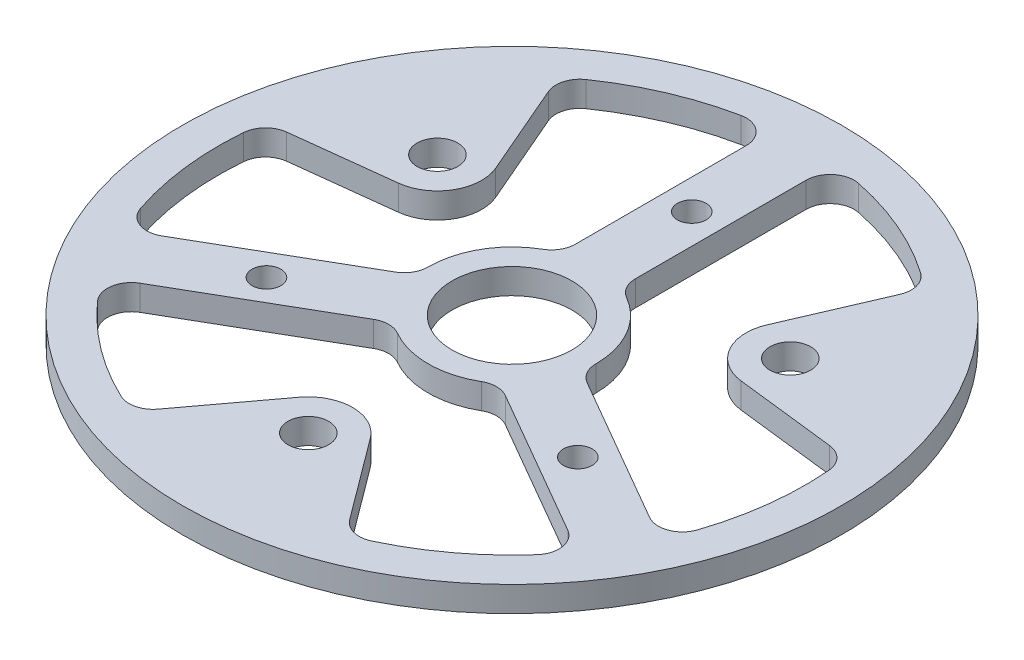
from build123d import *

# Parameters (mm, degrees)
CROQUIS1_R              = 27.5
SALIENTE_EXTRUIR1_DEPTH = 2.11
CROQUIS2_R              = 1.2
CROQUIS2_R_2            = 5
CROQUIS2_R_3            = 1.7
CORTAR_EXTRUIR1_DEPTH   = 3.11
REDONDEO1_R             = 2


with BuildPart() as part:
    # Croquis1 → Saliente-Extruir1 (new body)
    with BuildSketch(Plane(origin=(0, 0, 0), x_dir=(1, 0, 0), z_dir=(0, 1, 0))):
        Circle(CROQUIS1_R)
    extrude(amount=SALIENTE_EXTRUIR1_DEPTH)

    # Croquis2 → Cortar-Extruir1 (cut, through all)
    with BuildSketch(Plane(origin=(0, 2.11, 0), x_dir=(1, 0, 0), z_dir=(0, 1, 0))):
        with Locations((0, 15)):
            Circle(CROQUIS2_R)
        with Locations((12.990381057, -7.5)):
            Circle(CROQUIS2_R)
        with Locations((-12.990381057, -7.5)):
            Circle(CROQUIS2_R)
        Circle(CROQUIS2_R_2)
        with Locations((-14.722431864, 8.5)):
            Circle(CROQUIS2_R_3)
        with Locations((14.722431864, 8.5)):
            Circle(CROQUIS2_R_3)
        with Locations((0, -17)):
            Circle(CROQUIS2_R_3)
        with BuildLine():
            Line((-2.5, 6.538348415), (-2.5, 24.372115214))
            ThreePointArc((-2.5, 24.372115214), (-9.267968283, 22.679390731), (-15.28445201, 19.147729023))
            Line((-15.28445201, 19.147729023), (-11.324842647, 9.965055464))
            ThreePointArc((-11.324842647, 9.965055464), (-11.51813787, 6.65), (-14.292412506, 4.825073694))
            Line((-14.292412506, 4.825073694), (-24.224645764, 3.662859212))
            ThreePointArc((-24.224645764, 3.662859212), (-24.274912656, -3.313399391), (-22.356870919, -10.020994097))
            Line((-22.356870919, -10.020994097), (-6.912375826, -1.104110698))
            ThreePointArc((-6.912375826, -1.104110698), (-6.062177826, 3.5), (-2.5, 6.538348415))
        make_face()
        with BuildLine():
            Line((2.5, 6.538348415), (2.5, 24.372115214))
            ThreePointArc((2.5, 24.372115214), (9.267968283, 22.679390731), (15.28445201, 19.147729023))
            Line((15.28445201, 19.147729023), (11.324842647, 9.965055464))
            ThreePointArc((11.324842647, 9.965055464), (11.51813787, 6.65), (14.292412506, 4.825073694))
            Line((14.292412506, 4.825073694), (24.224645764, 3.662859212))
            ThreePointArc((24.224645764, 3.662859212), (24.274912656, -3.313399391), (22.356870919, -10.020994097))
            Line((22.356870919, -10.020994097), (6.912375826, -1.104110698))
            ThreePointArc((6.912375826, -1.104110698), (6.062177826, 3.5), (2.5, 6.538348415))
        make_face()
        with BuildLine():
            Line((4.412375826, -5.434237717), (19.856870919, -14.351121116))
            ThreePointArc((19.856870919, -14.351121116), (15.006944374, -19.36599134), (8.940193754, -22.810588235))
            Line((8.940193754, -22.810588235), (2.967569858, -14.790129159))
            ThreePointArc((2.967569858, -14.790129159), (0, -13.3), (-2.967569858, -14.790129159))
            Line((-2.967569858, -14.790129159), (-8.940193754, -22.810588235))
            ThreePointArc((-8.940193754, -22.810588235), (-15.006944374, -19.36599134), (-19.856870919, -14.351121116))
            Line((-19.856870919, -14.351121116), (-4.412375826, -5.434237717))
            ThreePointArc((-4.412375826, -5.434237717), (0, -7), (4.412375826, -5.434237717))
        make_face()
    extrude(amount=-CORTAR_EXTRUIR1_DEPTH, mode=Mode.SUBTRACT)

    # Redondeo1
    redondeo1_edges = [part.edges().sort_by_distance(p)[0] for p in [
        (6.912375826, 1.055, 1.104110698),
        (2.5, 1.055, -6.538348415),
        (2.5, 1.055, -24.372115214),
        (15.28445201, 1.055, -19.147729023),
        (24.224645764, 1.055, -3.662859212),
        (22.356870919, 1.055, 10.020994097),
        (-4.412375826, 1.055, 5.434237717),
        (4.412375826, 1.055, 5.434237717),
        (19.856870919, 1.055, 14.351121116),
        (8.940193754, 1.055, 22.810588235),
        (-8.940193754, 1.055, 22.810588235),
        (-19.856870919, 1.055, 14.351121116),
        (-2.5, 1.055, -6.538348415),
        (-6.912375826, 1.055, 1.104110698),
        (-22.356870919, 1.055, 10.020994097),
        (-24.224645764, 1.055, -3.662859212),
        (-15.28445201, 1.055, -19.147729023),
        (-2.5, 1.055, -24.372115214),
    ]]
    fillet(redondeo1_edges, radius=REDONDEO1_R)


solid = part.part
